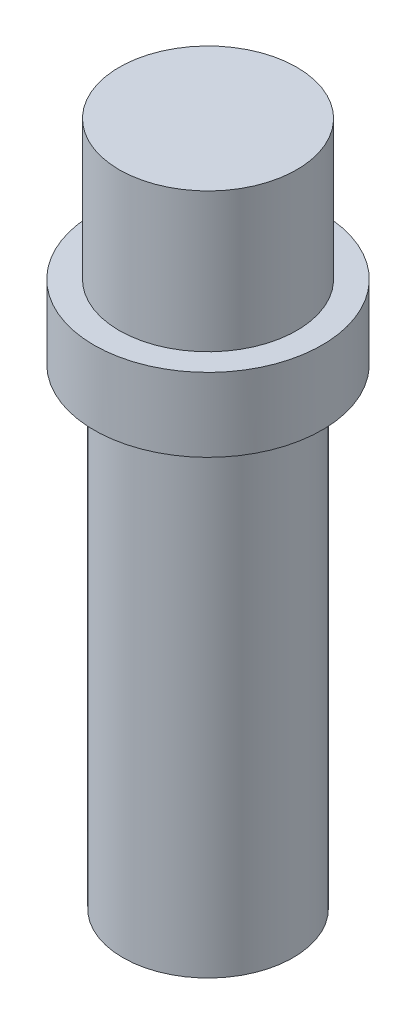
from build123d import *

# Parameters (mm, degrees)
SKETCH1_R           = 1.4
BOSS_EXTRUDE1_DEPTH = 11.25
SKETCH2_R           = 1.46
BOSS_EXTRUDE2_DEPTH = 3.5
SKETCH3_R           = 1.875
BOSS_EXTRUDE3_DEPTH = 1.21


with BuildPart() as part:
    # Sketch1 → Boss-Extrude1 (new body)
    with BuildSketch(Plane(origin=(0, 0, 0), x_dir=(1, 0, 0), z_dir=(0, 1, 0))):
        Circle(SKETCH1_R)
    extrude(amount=BOSS_EXTRUDE1_DEPTH)

    # Sketch2 → Boss-Extrude2 (add)
    with BuildSketch(Plane(origin=(0, 11.25, 0), x_dir=(1, 0, 0), z_dir=(0, 1, 0))):
        Circle(SKETCH2_R)
    extrude(amount=-BOSS_EXTRUDE2_DEPTH)

    # Sketch3 → Boss-Extrude3 (add)
    with BuildSketch(Plane.XZ.offset(-7.75)):
        Circle(SKETCH3_R)
    extrude(amount=-BOSS_EXTRUDE3_DEPTH)


solid = part.part
